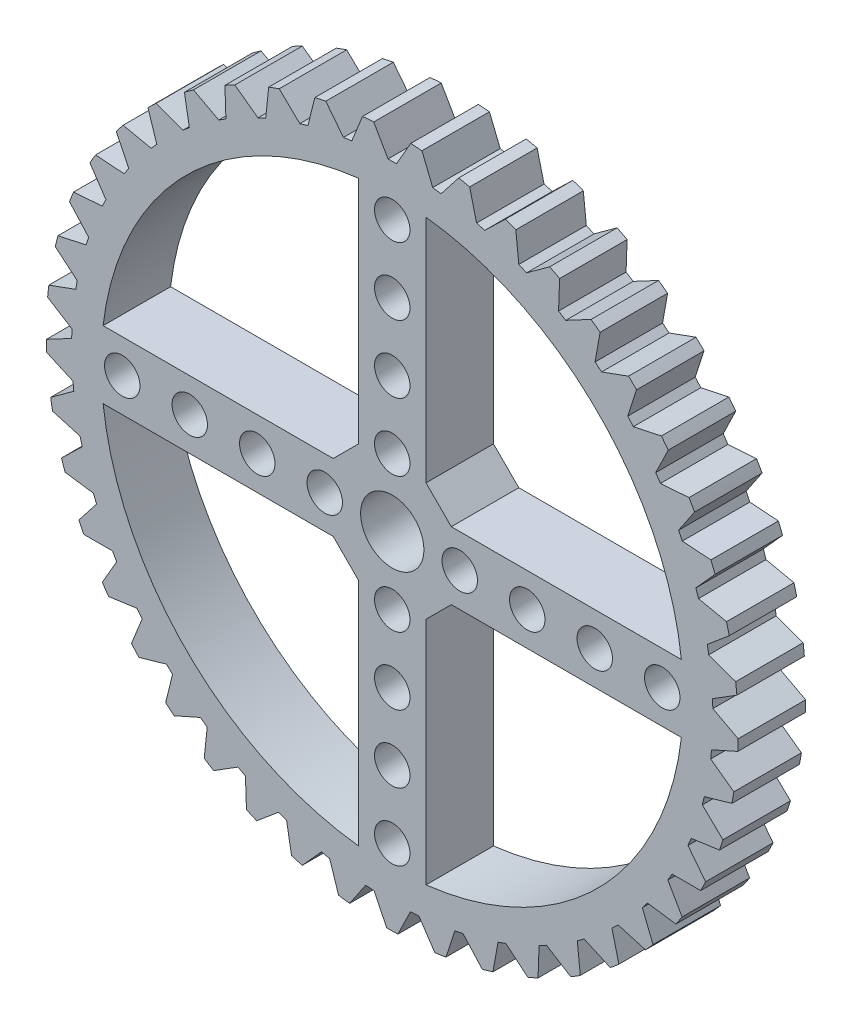
from build123d import *

# Parameters (mm, degrees)
SKETCH1_R           = 41
BOSS_EXTRUDE1_DEPTH = 8
CHAMFER1_SIZE       = 3
SKETCH2_R           = 3.75
SKETCH2_R_2         = 2.1
CUT_EXTRUDE1_DEPTH  = 10
CUT_EXTRUDE4_DEPTH  = 10
CIRPATTERN1_COUNT   = 45
CIRPATTERN2_COUNT   = 4


with BuildPart() as part:
    # Sketch1 → Boss-Extrude1 (new body)
    with BuildSketch(Plane.XY):
        Circle(SKETCH1_R)
        with BuildLine():
            Line((-4, 34.267331381), (-4, 4))
            Line((-4, 4), (-34.267331381, 4))
            ThreePointArc((-34.267331381, 4), (-24.395183951, 24.395183951), (-4, 34.267331381))
        make_face(mode=Mode.SUBTRACT)
        with BuildLine():
            Line((-34.267331381, -4), (-4, -4))
            Line((-4, -4), (-4, -34.267331381))
            ThreePointArc((-4, -34.267331381), (-24.395183951, -24.395183951), (-34.267331381, -4))
        make_face(mode=Mode.SUBTRACT)
        with BuildLine():
            Line((4, -34.267331381), (4, -4))
            Line((4, -4), (34.267331381, -4))
            ThreePointArc((34.267331381, -4), (24.395183951, -24.395183951), (4, -34.267331381))
        make_face(mode=Mode.SUBTRACT)
        with BuildLine():
            Line((34.267331381, 4), (4, 4))
            Line((4, 4), (4, 34.267331381))
            ThreePointArc((4, 34.267331381), (24.395183951, 24.395183951), (34.267331381, 4))
        make_face(mode=Mode.SUBTRACT)
    extrude(amount=BOSS_EXTRUDE1_DEPTH)

    # Chamfer1
    chamfer1_edges = [part.edges().sort_by_distance(p)[0] for p in [
        (-4, 4, 4),
        (4, 4, 4),
        (-4, -4, 4),
        (4, -4, 4),
    ]]
    chamfer(chamfer1_edges, length=CHAMFER1_SIZE)

    # Sketch2 → Cut-Extrude1 (cut)
    with BuildSketch(Plane.XY.offset(8)):
        Circle(SKETCH2_R)
        with Locations((-8, 0)):
            Circle(SKETCH2_R_2)
        with Locations((-16, 0)):
            Circle(SKETCH2_R_2)
        with Locations((-24, 0)):
            Circle(SKETCH2_R_2)
        with Locations((-32, 0)):
            Circle(SKETCH2_R_2)
    cut_extrude1 = extrude(amount=-CUT_EXTRUDE1_DEPTH, mode=Mode.SUBTRACT)

    # Sketch3 → Cut-Extrude4 (cut)
    with BuildSketch(Plane.XY.offset(8)):
        Polygon((-2.809401077, 42), (-0.5, 38), (0.5, 38), (2.809401077, 42), align=None)
    cut_extrude4 = extrude(amount=-CUT_EXTRUDE4_DEPTH, mode=Mode.SUBTRACT)

    # CirPattern1: Cut-Extrude4 ×45 about axis
    cirpattern1_axis = Axis((0, 0, 0), (0, 0, 1))
    for i in range(1, CIRPATTERN1_COUNT):
        add(cut_extrude4.rotate(cirpattern1_axis, i * 360 / CIRPATTERN1_COUNT), mode=Mode.SUBTRACT)

    # CirPattern2: Cut-Extrude1 ×4 about axis
    cirpattern2_axis = Axis((0, 0, 0), (0, 0, 1))
    for i in range(1, CIRPATTERN2_COUNT):
        add(cut_extrude1.rotate(cirpattern2_axis, i * 360 / CIRPATTERN2_COUNT), mode=Mode.SUBTRACT)


solid = part.part
